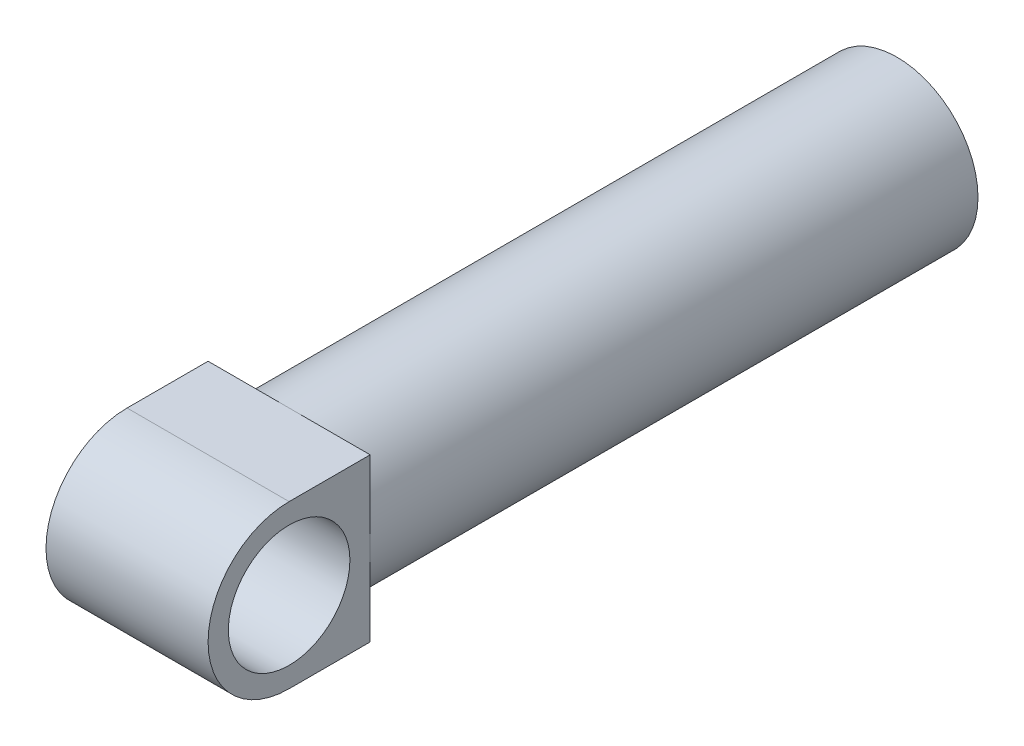
from build123d import *

# Parameters (mm, degrees)
SZKIC1_R                    = 40
DODANIE_WYCI_GNI_CIE1_DEPTH = 300
DODANIE_WYCI_GNI_CIE2_DEPTH = 40
SZKIC3_R                    = 30
WYTNIJ_WYCI_GNI_CIE1_DEPTH  = 81


with BuildPart() as part:
    # Szkic1 → Dodanie-wyciągnięcie1 (new body)
    with BuildSketch(Plane.XY):
        Circle(SZKIC1_R)
    extrude(amount=DODANIE_WYCI_GNI_CIE1_DEPTH)

    # Szkic2 → Dodanie-wyciągnięcie2 (add, symmetric)
    with BuildSketch(Plane(origin=(0, 0, 0), x_dir=(0, 0, -1), z_dir=(1, 0, 0))):
        with BuildLine():
            Line((-340, -40), (-300, -40))
            Line((-300, -40), (-300, 40))
            Line((-300, 40), (-340, 40))
            ThreePointArc((-340, 40), (-380, 0), (-340, -40))
        make_face()
    extrude(amount=DODANIE_WYCI_GNI_CIE2_DEPTH, both=True)

    # Szkic3 → Wytnij-wyciągnięcie1 (cut, through all)
    with BuildSketch(Plane(origin=(40, 0, 0), x_dir=(0, 0, -1), z_dir=(1, 0, 0))):
        with Locations((-340, 0)):
            Circle(SZKIC3_R)
    extrude(amount=-WYTNIJ_WYCI_GNI_CIE1_DEPTH, mode=Mode.SUBTRACT)


solid = part.part
